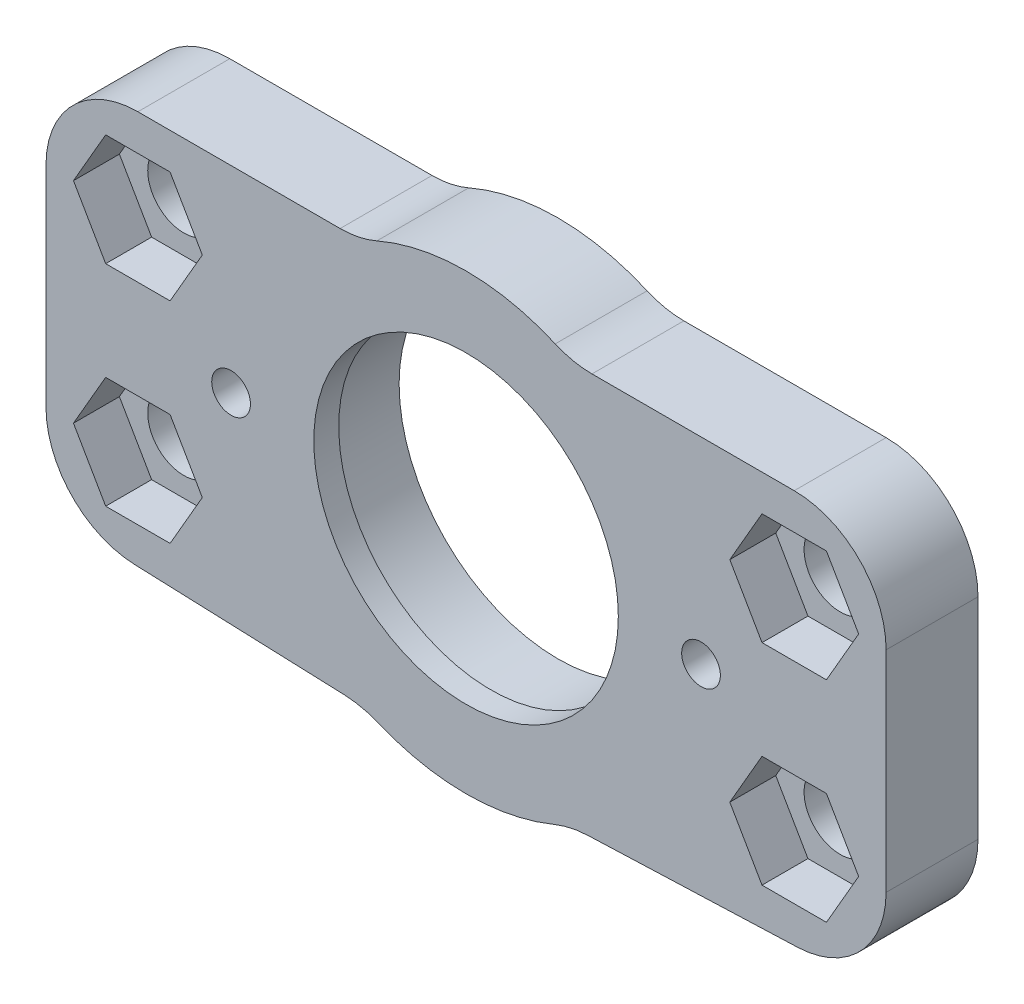
from build123d import *

# Parameters (mm, degrees)
SKETCH_1_R          = 12.1
EXTRUDE_1_DEPTH     = 7
FILLET_3_R          = 7
SKETCH_7_R          = 12.1
SKETCH_7_R_2        = 11.6
EXTRUDE_2_DEPTH     = 1.9
HOLE_WIZARD_M53_D   = 5.5
HOLE_WIZARD_M54_D   = 5.5
CUT_EXTRUDE_1_DEPTH = 3.5
SKETCH1_R           = 1.475614807
CUT_EXTRUDE1_DEPTH  = 10


with BuildPart() as part:
    # Эскиз1 → Бобышка-Вытянуть1 (new body)
    with BuildSketch(Plane.XY):
        with BuildLine():
            Line((-9.282257481, -15.602398743), (-25.265839773, -14.994950265))
            ThreePointArc((-25.265839773, -14.994950265), (-30.042860221, -12.854849204), (-32, -8))
            Line((-32, -8), (-32, 15))
            Line((-32, 15), (-8, 15))
            ThreePointArc((-8, 15), (0, 17), (8, 15))
            Line((8, 15), (32, 15))
            Line((32, 15), (32, -8))
            ThreePointArc((32, -8), (30.042860221, -12.854849204), (25.265839773, -14.994950265))
            Line((25.265839773, -14.994950265), (9.282257481, -15.602398743))
            ThreePointArc((9.282257481, -15.602398743), (7.964469385, -15.770214084), (6.696960066, -16.167891819))
            ThreePointArc((6.696960066, -16.167891819), (0, -17.5), (-6.696960066, -16.167891819))
            ThreePointArc((-6.696960066, -16.167891819), (-7.964469385, -15.770214084), (-9.282257481, -15.602398743))
        make_face()
        Circle(SKETCH_1_R, mode=Mode.SUBTRACT)
    extrude(amount=EXTRUDE_1_DEPTH)

    # Скругление3
    fillet_3_edges = [part.edges().sort_by_distance(p)[0] for p in [
        (-32, 15, 3.5),
        (-8, 15, 3.5),
        (8, 15, 3.5),
        (32, 15, 3.5),
    ]]
    fillet(fillet_3_edges, radius=FILLET_3_R)

    # Эскиз7 → Бобышка-Вытянуть2 (add)
    with BuildSketch(Plane.XY.offset(7)):
        Circle(SKETCH_7_R)
        Circle(SKETCH_7_R_2, mode=Mode.SUBTRACT)
    extrude(amount=-EXTRUDE_2_DEPTH)

    # Отверстие с зазором M53 (through all)
    with Locations(Plane.XY.offset(7)):
        with Locations((-25, 8), (25, 8)):
            Hole(HOLE_WIZARD_M53_D / 2)

    # Отверстие с зазором M54 (through all)
    with Locations(Plane(origin=(-20.850360387, 7.199740636, 7), x_dir=(-1, 0, 0), z_dir=(0, 0, 1))):
        with Locations((-45.850360387, 15.199740636), (4.149639613, 15.199740636)):
            Hole(HOLE_WIZARD_M54_D / 2)

    # Эскиз18 → Вырез-Вытянуть1 (cut)
    with BuildSketch(Plane(origin=(0, 0, 7), x_dir=(1, 0, 0), z_dir=(0, 0, -1))):
        Polygon((20.092522712, -8), (22.546261356, -12.25), (27.453738644, -12.25), (29.907477288, -8), (27.453738644, -3.75), (22.546261356, -3.75), align=None)
        Polygon((-27.453738644, -3.75), (-29.907477288, -8), (-27.453738644, -12.25), (-22.546261356, -12.25), (-20.092522712, -8), (-22.546261356, -3.75), align=None)
        Polygon((20.092522712, 8), (22.546261356, 12.25), (27.453738644, 12.25), (29.907477288, 8), (27.453738644, 3.75), (22.546261356, 3.75), align=None)
        Polygon((-22.546261356, 12.25), (-20.092522712, 8), (-22.546261356, 3.75), (-27.453738644, 3.75), (-29.907477288, 8), (-27.453738644, 12.25), align=None)
    extrude(amount=CUT_EXTRUDE_1_DEPTH, mode=Mode.SUBTRACT)

    # Sketch1 → Cut-Extrude1 (cut)
    with BuildSketch(Plane.XY):
        with Locations((17.9, 0)):
            Circle(SKETCH1_R)
        with Locations((-17.9, 0)):
            Circle(SKETCH1_R)
    extrude(amount=CUT_EXTRUDE1_DEPTH, mode=Mode.SUBTRACT)


solid = part.part
